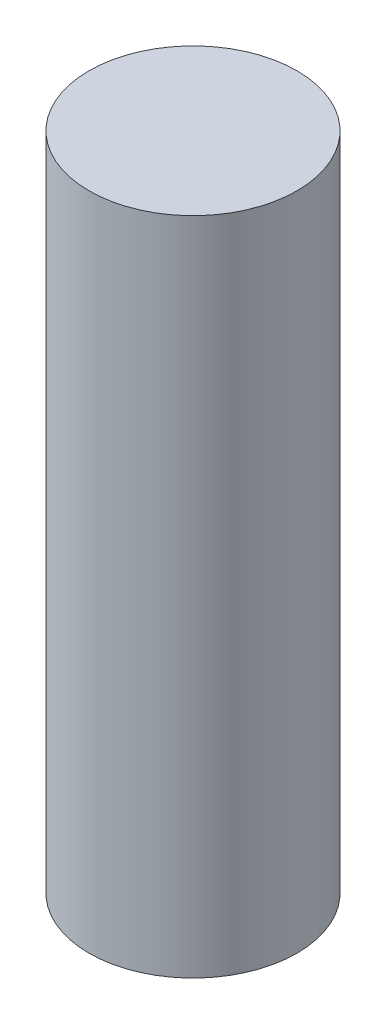
from build123d import *

# Parameters (mm, degrees)
SKETCH1_R        = 2
DOWEL_BODY_DEPTH = 12.7


with BuildPart() as part:
    # Sketch1 → dowel_body (new body)
    with BuildSketch(Plane(origin=(0, 0, 0), x_dir=(1, 0, 0), z_dir=(0, 1, 0))):
        Circle(SKETCH1_R)
    extrude(amount=DOWEL_BODY_DEPTH)


solid = part.part
